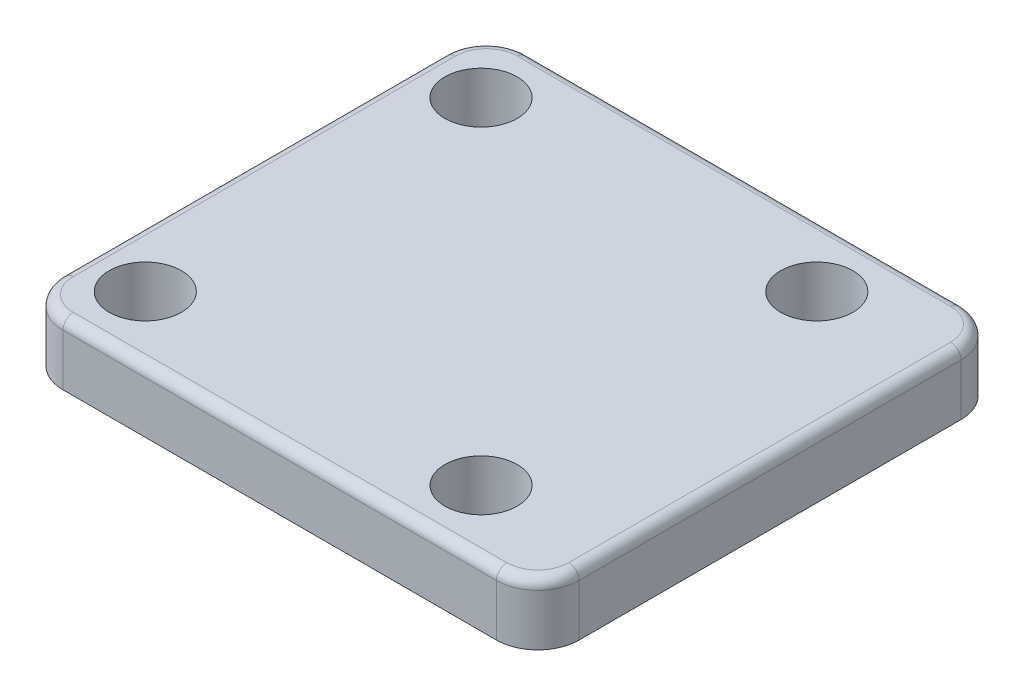
from build123d import *

# Parameters (mm, degrees)
BOSS_EXTRUDE1_DEPTH = 6
FILLET1_R           = 1
SKETCH2_R           = 16
BOSS_EXTRUDE2_DEPTH = 2
CHAMFER1_SIZE       = 1
CHAMFER1_SIZE2      = 1.732050808
SKETCH3_R           = 3.5
CUT_EXTRUDE1_DEPTH  = 9


with BuildPart() as part:
    # Sketch1 → Boss-Extrude1 (new body)
    with BuildSketch(Plane(origin=(0, 0, 0), x_dir=(1, 0, 0), z_dir=(0, 1, 0))):
        with BuildLine():
            Line((-18, 22.5), (24, 22.5))
            ThreePointArc((24, 22.5), (26.828427125, 21.328427125), (28, 18.5))
            Line((28, 18.5), (28, -18.5))
            ThreePointArc((28, -18.5), (26.828427125, -21.328427125), (24, -22.5))
            Line((24, -22.5), (-18, -22.5))
            ThreePointArc((-18, -22.5), (-20.828427125, -21.328427125), (-22, -18.5))
            Line((-22, -18.5), (-22, 18.5))
            ThreePointArc((-22, 18.5), (-20.828427125, 21.328427125), (-18, 22.5))
        make_face()
    extrude(amount=BOSS_EXTRUDE1_DEPTH)

    # Fillet1
    fillet1_edges = [part.edges().sort_by_distance(p)[0] for p in [
        (-20.828427125, 6, -21.328427125),
        (-22, 6, 0),
        (-20.828427125, 6, 21.328427125),
        (3, 6, 22.5),
        (26.828427125, 6, 21.328427125),
        (28, 6, 0),
        (26.828427125, 6, -21.328427125),
        (3, 6, -22.5),
    ]]
    fillet(fillet1_edges, radius=FILLET1_R)

    # Sketch2 → Boss-Extrude2 (add)
    with BuildSketch(Plane.XZ):
        Circle(SKETCH2_R)
    extrude(amount=BOSS_EXTRUDE2_DEPTH)

    # Chamfer1
    chamfer1_edges = [part.edges().sort_by_distance(p)[0] for p in [
        (-16, -2, 0),
    ]]
    chamfer1_side = [part.faces().sort_by_distance(p)[0] for p in [
        (-16, -1, 0),
    ]]
    chamfer(chamfer1_edges, length=CHAMFER1_SIZE, length2=CHAMFER1_SIZE2, reference=chamfer1_side[0])

    # Sketch3 → Cut-Extrude1 (cut, through all)
    with BuildSketch(Plane(origin=(0, 6, 0), x_dir=(1, 0, 0), z_dir=(0, 1, 0))):
        with Locations((-16.263455967, 16.263455967)):
            Circle(SKETCH3_R)
        with Locations((16.263455967, 16.263455967)):
            Circle(SKETCH3_R)
        with Locations((16.263455967, -16.263455967)):
            Circle(SKETCH3_R)
        with Locations((-16.263455967, -16.263455967)):
            Circle(SKETCH3_R)
    extrude(amount=-CUT_EXTRUDE1_DEPTH, mode=Mode.SUBTRACT)


solid = part.part
